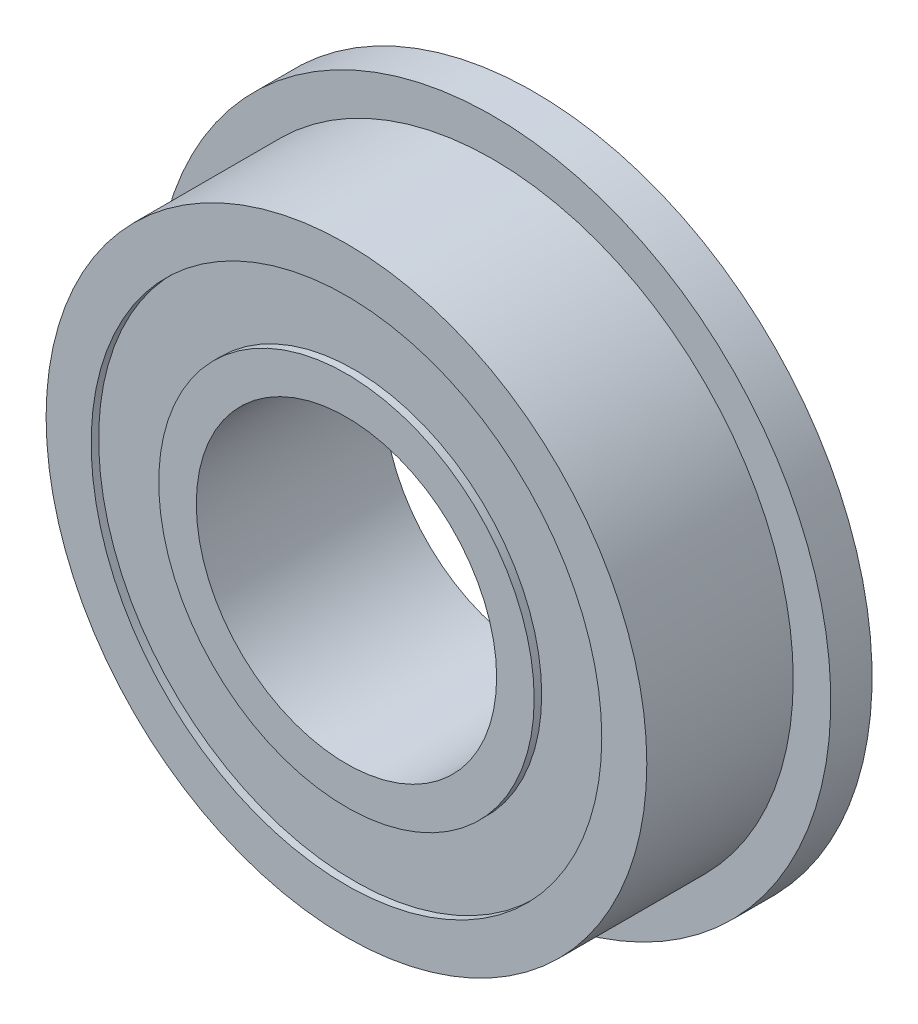
from build123d import *

# Parameters (mm, degrees)
SKETCH_1_R          = 8
EXTRUDE_1_DEPTH     = 2.5
SKETCH_4_R          = 9
EXTRUDE_2_DEPTH     = 1.1
SKETCH_2_R          = 4
CUT_EXTRUDE_1_DEPTH = 6
SKETCH_3_R          = 6.8
SKETCH_3_R_2        = 5
CUT_EXTRUDE_2_DEPTH = 0.2


with BuildPart() as part:
    # 草圖1 → 填料-伸長1 (new body, symmetric)
    with BuildSketch(Plane.XY):
        Circle(SKETCH_1_R)
    extrude(amount=EXTRUDE_1_DEPTH, both=True)

    # 草圖4 → 填料-伸長2 (add)
    with BuildSketch(Plane(origin=(0, 0, -2.5), x_dir=(-1, 0, 0), z_dir=(0, 0, -1))):
        Circle(SKETCH_4_R)
    extrude(amount=-EXTRUDE_2_DEPTH)

    # 草圖2 → 除料-伸長1 (cut, through all)
    with BuildSketch(Plane.XY.offset(2.5)):
        Circle(SKETCH_2_R)
    extrude(amount=-CUT_EXTRUDE_1_DEPTH, mode=Mode.SUBTRACT)

    # 草圖3 → 除料-伸長2 (cut)
    with BuildSketch(Plane.XY.offset(2.5)):
        Circle(SKETCH_3_R)
        Circle(SKETCH_3_R_2, mode=Mode.SUBTRACT)
    cut_extrude_2 = extrude(amount=-CUT_EXTRUDE_2_DEPTH, mode=Mode.SUBTRACT)

    # 鏡射1: 除料-伸長2 across plane
    add(cut_extrude_2.mirror(Plane.XY), mode=Mode.SUBTRACT)


solid = part.part
